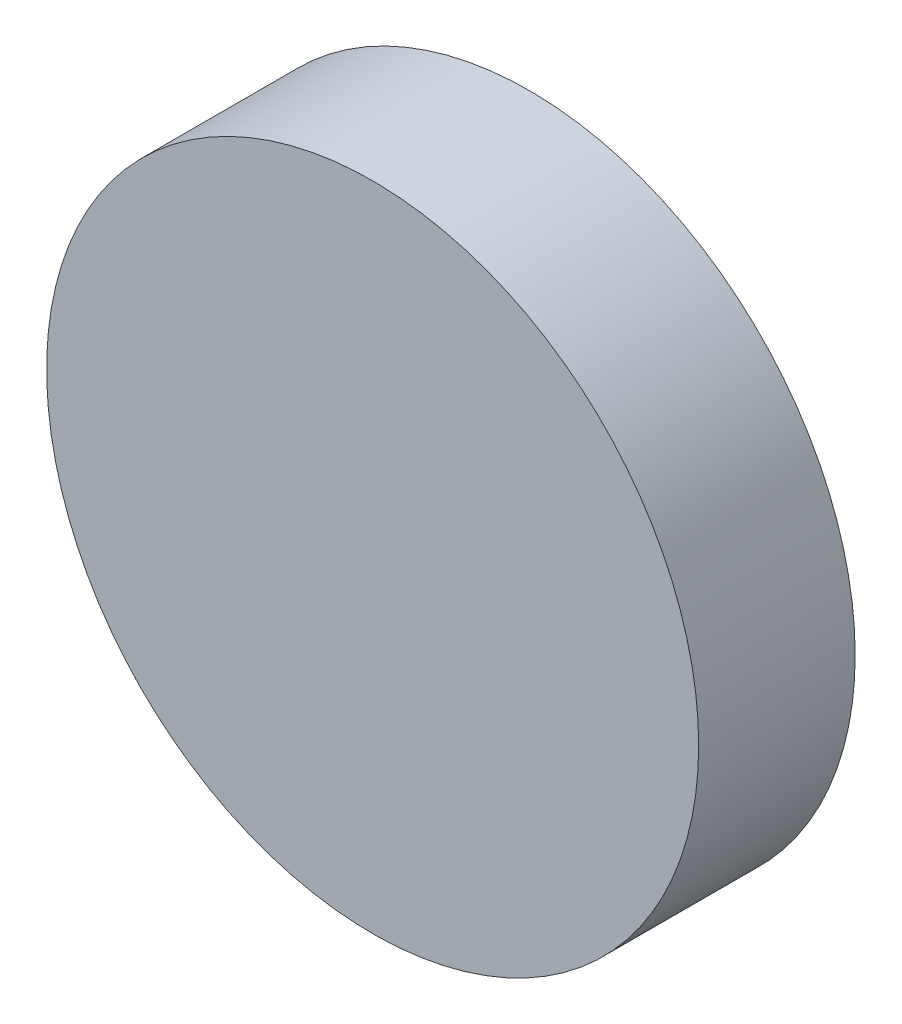
from build123d import *

# Parameters (mm, degrees)
SKETCH2_R          = 37.5
BASE_EXTRUDE_DEPTH = 18


with BuildPart() as part:
    # Sketch2 → Base-Extrude (new body)
    with BuildSketch(Plane.XY):
        Circle(SKETCH2_R)
    extrude(amount=BASE_EXTRUDE_DEPTH)


solid = part.part
